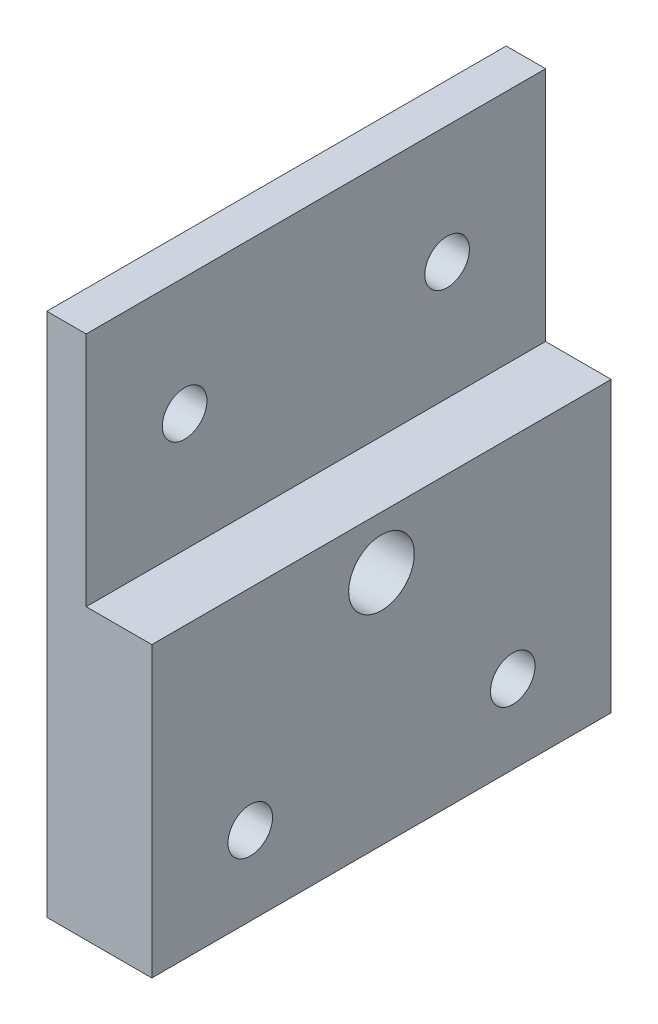
from build123d import *

# Parameters (mm, degrees)
BOSS_EXTRUDE1_DEPTH            = 35
M3_CLEARANCE_HOLE2_D           = 3.4
CBORE_FOR_M3_SHCS1_D           = 3.4
CBORE_FOR_M3_SHCS1_CBORE_D     = 6.5
CBORE_FOR_M3_SHCS1_CBORE_DEPTH = 3
TAP_DRILL_FOR_M6X1_0_TAP1_D    = 5


with BuildPart() as part:
    # Sketch1 → Boss-Extrude1 (new body)
    with BuildSketch(Plane.XY):
        Polygon((0, 9), (-3, 9), (-3, -31), (0, -31), (5, -31), (5, -9), (0, -9), align=None)
    extrude(amount=-BOSS_EXTRUDE1_DEPTH)

    # M3 Clearance Hole2 (through all)
    with Locations(Plane.ZY.offset(3)):
        with Locations((-7.5, 0), (-27.5, 0)):
            Hole(M3_CLEARANCE_HOLE2_D / 2)

    # CBORE for M3 SHCS1 (through all)
    with Locations(Plane.ZY.offset(3)):
        with Locations((-7.5, -25), (-27.5, -25)):
            CounterBoreHole(CBORE_FOR_M3_SHCS1_D / 2, CBORE_FOR_M3_SHCS1_CBORE_D / 2, CBORE_FOR_M3_SHCS1_CBORE_DEPTH)

    # Tap Drill for M6x1.0 Tap1 (through all)
    with Locations(Plane.ZY.offset(3)):
        with Locations((-17.5, -13)):
            Hole(TAP_DRILL_FOR_M6X1_0_TAP1_D / 2)


solid = part.part
